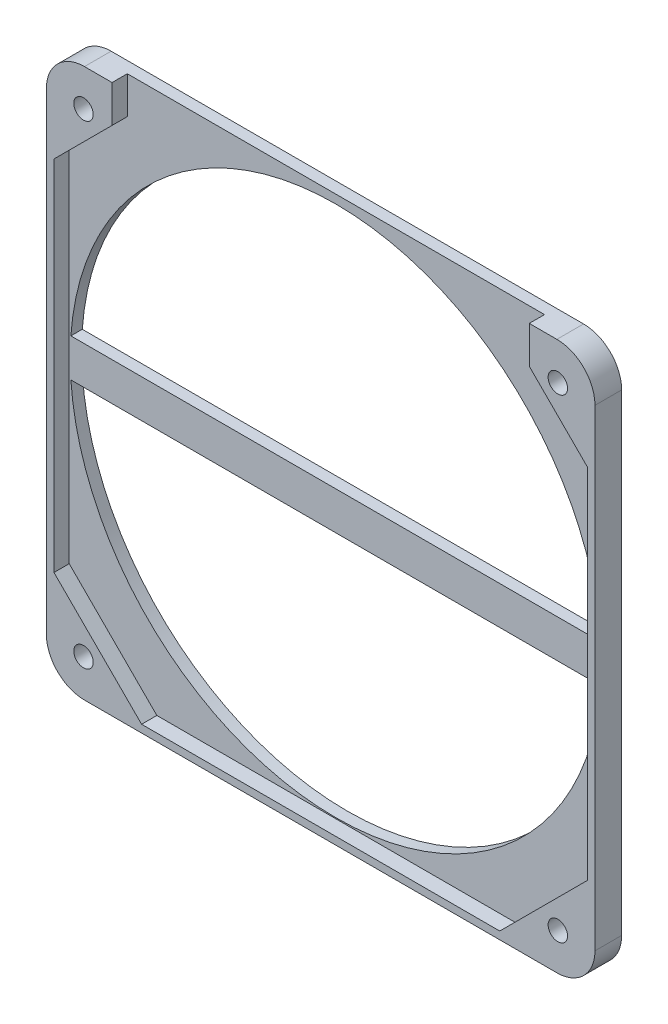
from build123d import *

# Parameters (mm, degrees)
SKICA1_W                          = 144
SKICA1_H                          = 144
P_IDAT_VYSUNUT_M1_DEPTH           = 7
D_RY_PRO_KOL_K_VELIKOST_MM1_D     = 5.1
D_RY_PRO_KOL_K_VELIKOST_MM1_DEPTH = 6
ODEBRAT_VYSUNUT_M1_DEPTH          = 4
ODEBRAT_VYSUNUT_M2_DEPTH          = 102.901913623
ZAOBLIT1_R                        = 10


with BuildPart() as part:
    # Skica1 → Přidat vysunutím1 (new body)
    with BuildSketch(Plane.XY):
        Rectangle(SKICA1_W, SKICA1_H)
    extrude(amount=P_IDAT_VYSUNUT_M1_DEPTH)

    # Díry pro kolík, velikost mm1
    with Locations(Plane.XY.offset(7)):
        with Locations((-62.25, -62.25), (-62.25, 62.25), (62.25, 62.25), (62.25, -62.25)):
            Hole(D_RY_PRO_KOL_K_VELIKOST_MM1_D / 2, depth=D_RY_PRO_KOL_K_VELIKOST_MM1_DEPTH)

    # Skica5 → Odebrat vysunutím1 (cut)
    with BuildSketch(Plane.XY.offset(7)):
        Polygon((-70, -47), (-47, -70), (47, -70), (70, -47), (70, 47), (54.75233406, 62.24766594), (54.75233406, 72), (-54.75233406, 72), (-54.75233406, 62.24766594), (-70, 47), align=None)
    extrude(amount=-ODEBRAT_VYSUNUT_M1_DEPTH, mode=Mode.SUBTRACT)

    # Skica6 → Odebrat vysunutím2 (cut, through all)
    with BuildSketch(Plane.XY.offset(3)):
        with BuildLine():
            ThreePointArc((69.570557709, 5), (0, 69.75), (-69.570557709, 5))
            Line((-69.570557709, 5), (69.570557709, 5))
        make_face()
        with BuildLine():
            Line((69.570557709, -5), (-69.570557709, -5))
            ThreePointArc((-69.570557709, -5), (0, -69.75), (69.570557709, -5))
        make_face()
    extrude(amount=-ODEBRAT_VYSUNUT_M2_DEPTH, mode=Mode.SUBTRACT)

    # Zaoblit1
    zaoblit1_edges = [part.edges().sort_by_distance(p)[0] for p in [
        (72, -72, 3.5),
        (-72, -72, 3.5),
        (-72, 72, 3.5),
        (72, 72, 3.5),
    ]]
    fillet(zaoblit1_edges, radius=ZAOBLIT1_R)


solid = part.part
